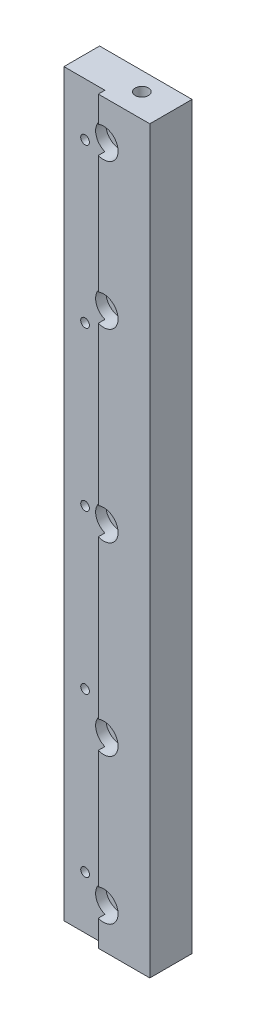
from build123d import *

# Parameters (mm, degrees)
SKETCH1_W                                           = 35
SKETCH1_H                                           = 280
EXTRUDE1_DEPTH                                      = 16
EXTRUDE2_REACH                                      = 282
SKETCH2_W                                           = 15.5
SKETCH2_H                                           = 2.5
M4_TAPPED_HOLE1_D                                   = 3.3
M6_TAPPED_HOLE1_D                                   = 5
CBORE_FOR_M6_HEX_SOCKET_HEAD_CAP_SCREW1_D           = 6.6
CBORE_FOR_M6_HEX_SOCKET_HEAD_CAP_SCREW1_DEPTH       = 29
CBORE_FOR_M6_HEX_SOCKET_HEAD_CAP_SCREW1_CBORE_D     = 11
CBORE_FOR_M6_HEX_SOCKET_HEAD_CAP_SCREW1_CBORE_DEPTH = 6.4
CBORE_FOR_M6_HEX_SOCKET_HEAD_CAP_SCREW1_TIP         = 1.982840043


with BuildPart() as part:
    # Sketch1 → Extrude1 (new body)
    with BuildSketch(Plane.XY):
        Rectangle(SKETCH1_W, SKETCH1_H)
    extrude(amount=EXTRUDE1_DEPTH)

    # Sketch2 → Extrude2 (cut, up to next)
    with BuildSketch(Plane.XZ.offset(140), mode=Mode.PRIVATE) as extrude2_sk1:
        with Locations((-9.75, 14.75)):
            Rectangle(SKETCH2_W, SKETCH2_H)
    extrude2_tool1 = extrude(extrude2_sk1.sketch, amount=-EXTRUDE2_REACH, mode=Mode.PRIVATE) & part.part
    add(extrude2_tool1.solids().sort_by_distance((-9.75, -140, 14.75))[0], mode=Mode.SUBTRACT)

    # M4 Tapped Hole1 (through all)
    with Locations(Plane.XY.offset(13.5)):
        with Locations((-9.5, -120), (-9.5, -60), (-9.5, 0), (-9.5, 60), (-9.5, 120)):
            Hole(M4_TAPPED_HOLE1_D / 2)

    # M6 Tapped Hole1 (through all)
    with Locations(Plane(origin=(0, -140, 0), x_dir=(-1, 0, 0), z_dir=(0, -1, 0))):
        with Locations((-5.5, -7)):
            Hole(M6_TAPPED_HOLE1_D / 2)

    # CBORE for M6 Hex Socket Head Cap Screw1
    with Locations(Plane.XY.offset(16)):
        with Locations((0, 125), (0, 70), (0, 0), (0, -70), (0, -125)):
            CounterBoreHole(CBORE_FOR_M6_HEX_SOCKET_HEAD_CAP_SCREW1_D / 2, CBORE_FOR_M6_HEX_SOCKET_HEAD_CAP_SCREW1_CBORE_D / 2, CBORE_FOR_M6_HEX_SOCKET_HEAD_CAP_SCREW1_CBORE_DEPTH, depth=CBORE_FOR_M6_HEX_SOCKET_HEAD_CAP_SCREW1_DEPTH)
            with Locations((0, 0, -(CBORE_FOR_M6_HEX_SOCKET_HEAD_CAP_SCREW1_DEPTH + CBORE_FOR_M6_HEX_SOCKET_HEAD_CAP_SCREW1_TIP / 2))):  # 118° drill point
                Cone(0, CBORE_FOR_M6_HEX_SOCKET_HEAD_CAP_SCREW1_D / 2, CBORE_FOR_M6_HEX_SOCKET_HEAD_CAP_SCREW1_TIP, mode=Mode.SUBTRACT)


solid = part.part
